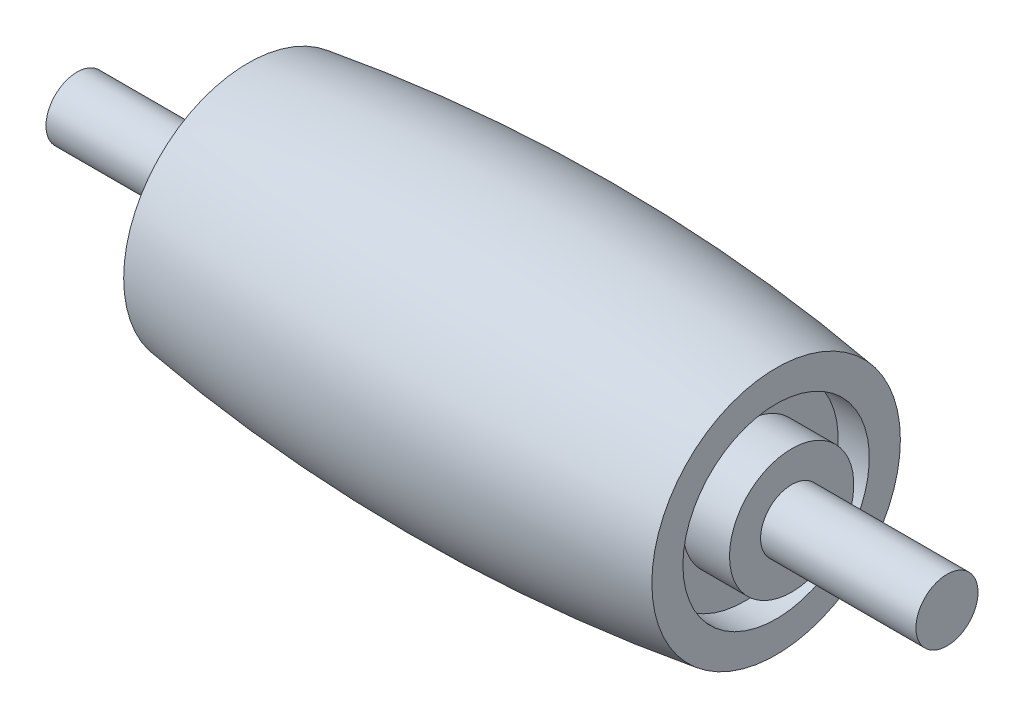
from build123d import *

# Parameters (mm, degrees)
SKETCH_2_R          = 3
SKETCH_2_R_2        = 2
CUT_EXTRUDE_1_DEPTH = 1
SKETCH_3_R          = 2
EXTRUDE_1_DEPTH     = 0.5
SKETCH_5_R          = 1
EXTRUDE_3_DEPTH     = 5


with BuildPart() as part:
    # 草图1 → 旋转2 (revolve)
    with BuildSketch(Plane.XY):
        with BuildLine():
            Line((7.513582187, 0), (7.513582187, -4))
            ThreePointArc((7.513582187, -4), (16.013582187, -4.614003224), (24.513582187, -4))
            Line((24.513582187, -4), (24.513582187, 0))
            Line((24.513582187, 0), (7.513582187, 0))
        make_face()
    revolve(axis=Axis((7.513582187, 0, 0), (1, 0, 0)))

    # 草图2 → 切除-拉伸1 (cut)
    with BuildSketch(Plane.ZY.offset(-7.513582187)):
        Circle(SKETCH_2_R)
        Circle(SKETCH_2_R_2, mode=Mode.SUBTRACT)
    cut_extrude_1 = extrude(amount=-CUT_EXTRUDE_1_DEPTH, mode=Mode.SUBTRACT)

    # 草图3 → 凸台-拉伸1 (add)
    with BuildSketch(Plane.ZY.offset(-7.513582187)):
        Circle(SKETCH_3_R)
    extrude_1 = extrude(amount=EXTRUDE_1_DEPTH)

    # 草图5 → 凸台-拉伸3 (add)
    with BuildSketch(Plane.ZY.offset(-7.013582187)):
        Circle(SKETCH_5_R)
    extrude_3 = extrude(amount=EXTRUDE_3_DEPTH)

    # 镜向4: 切除-拉伸1, 凸台-拉伸1, 凸台-拉伸3 across plane
    add(cut_extrude_1.mirror(Plane.ZY.offset(-16.013582187)), mode=Mode.SUBTRACT)
    add(extrude_1.mirror(Plane.ZY.offset(-16.013582187)))
    add(extrude_3.mirror(Plane.ZY.offset(-16.013582187)))


solid = part.part
